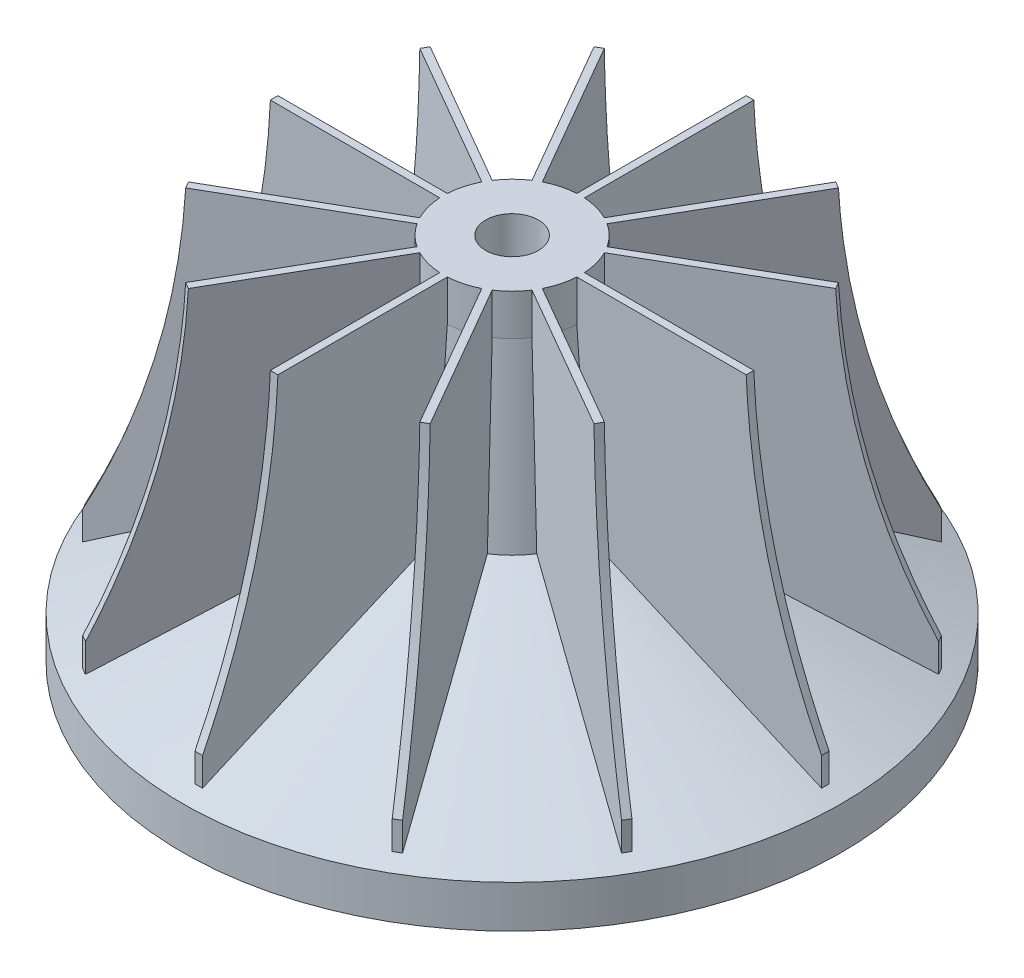
from build123d import *

# Parameters (mm, degrees)
BOSS_EXTRUDE5_START = -38.519606
BOSS_EXTRUDE5_DEPTH = 38.519606
CIRPATTERN8_COUNT   = 12
CUT_EXTRUDE1_REACH  = 46.45
SKETCH6_R           = 3.175


with BuildPart() as part:
    # Sketch1 → Revolve1 (revolve)
    with BuildSketch(Plane.XY):
        Polygon((0, 0), (-39.624, 0), (-39.624, 5.08), (-9.822923796, 18.069281233), (-8.255, 39.518150017), (-8.255, 44.45), (0, 44.45), align=None)
    revolve(axis=Axis((0, 0, 0), (0, 1, 0)))

    # Sketch3 → Boss-Extrude5 (add)
    with BuildSketch(Plane(origin=(0, 44.45, 0), x_dir=(1, 0, 0), z_dir=(0, 1, 0)).offset(BOSS_EXTRUDE5_START)):
        with BuildLine():
            Line((0.455930282, -37.670191496), (0.455991802, -8.206191496))
            add(Edge.make_bspline(
                [(-0.45593, -8.206191496), (3.0201e-05, -8.303808504), (0.455991802, -8.206191496)],
                knots=[0, 0, 0, 1, 1, 1], degree=2))
            Line((-0.45593, -8.206191496), (-0.45593, -37.670191496))
            Line((-0.45593, -37.670191496), (0.455930282, -37.670191496))
        make_face()
    boss_extrude5 = extrude(amount=BOSS_EXTRUDE5_DEPTH)

    # CirPattern8: Boss-Extrude5 ×12 about axis
    cirpattern8_axis = Axis((0, 0, 0), (0, 1, 0))
    for i in range(1, CIRPATTERN8_COUNT):
        add(boss_extrude5.rotate(cirpattern8_axis, i * 360 / CIRPATTERN8_COUNT))

    # Sketch7 → Cut-Revolve3 (revolve, cut)
    with BuildSketch(Plane(origin=(0, 0, 0), x_dir=(0, 0, -1), z_dir=(1, 0, 0))):
        with BuildLine():
            Line((-42.13340627, 53.486181243), (-28.575, 53.486181243))
            Line((-28.575, 53.486181243), (-28.575, 45.258268752))
            add(Edge.make_bspline(
                [(-28.575, 45.258268752), (-29.259976599, 26.307663759), (-37.670191496, 9.339538931)],
                knots=[0, 0, 0, 1, 1, 1], degree=2))
            Line((-37.670191496, 9.339538931), (-42.68469114, 9.339538931))
            Line((-42.68469114, 9.339538931), (-42.13340627, 53.486181243))
        make_face()
    revolve(axis=Axis((0, 0, 0), (0, 1, 0)), mode=Mode.SUBTRACT)

    # Sketch6 → Cut-Extrude1 (cut, up to next)
    with BuildSketch(Plane(origin=(0, 44.45, 0), x_dir=(1, 0, 0), z_dir=(0, 1, 0)), mode=Mode.PRIVATE) as cut_extrude1_sk1:
        Circle(SKETCH6_R)
    cut_extrude1_tool1 = extrude(cut_extrude1_sk1.sketch, amount=-CUT_EXTRUDE1_REACH, mode=Mode.PRIVATE) & part.part
    add(cut_extrude1_tool1.solids().sort_by_distance((0, 44.45, 0))[0], mode=Mode.SUBTRACT)


solid = part.part
